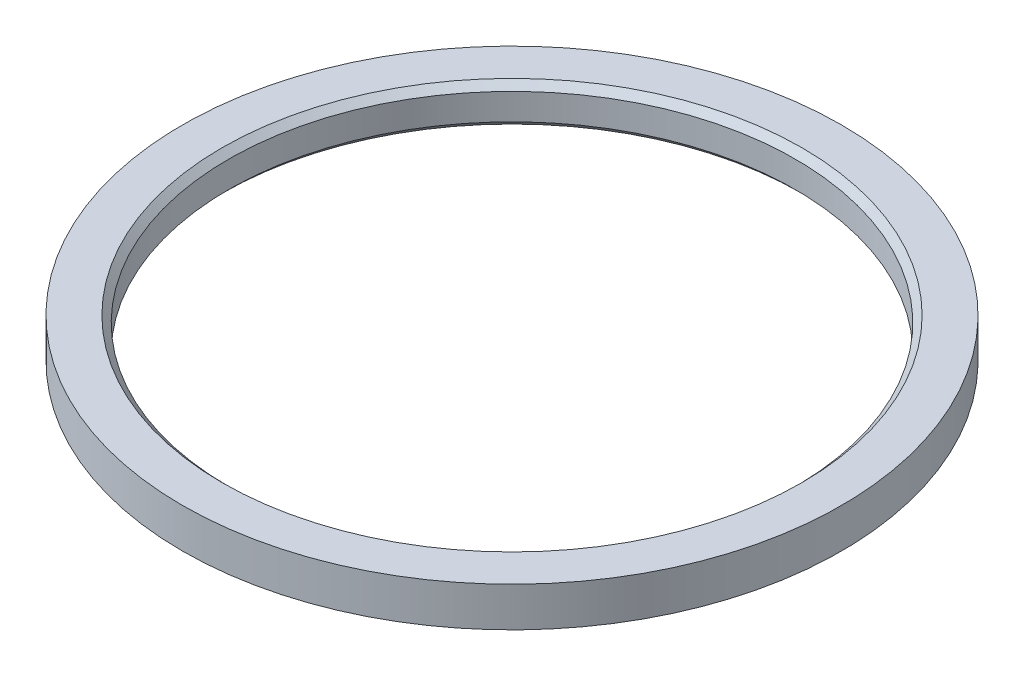
from build123d import *

# Parameters (mm, degrees)
SKETCH_1_R      = 10
SKETCH_1_R_2    = 8.6
EXTRUDE_1_DEPTH = 1.2
CHAMFER_1_SIZE  = 0.2


with BuildPart() as part:
    # 草图1 → 凸台-拉伸1 (new body)
    with BuildSketch(Plane(origin=(0, 0, 0), x_dir=(1, 0, 0), z_dir=(0, 1, 0))):
        Circle(SKETCH_1_R)
        Circle(SKETCH_1_R_2, mode=Mode.SUBTRACT)
    extrude(amount=EXTRUDE_1_DEPTH)

    # 倒角1
    chamfer_1_edges = [part.edges().sort_by_distance(p)[0] for p in [
        (-8.6, 0, 0),
        (-8.6, 1.2, 0),
    ]]
    chamfer(chamfer_1_edges, length=CHAMFER_1_SIZE)


solid = part.part
